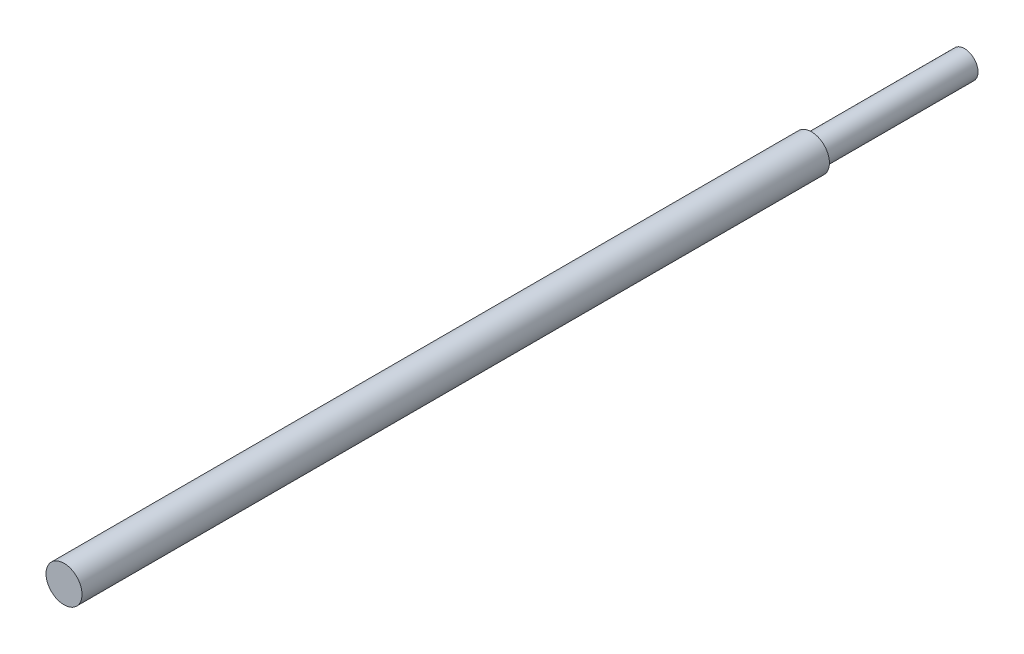
from build123d import *

# Parameters (mm, degrees)
SKETCH1_R           = 8
BOSS_EXTRUDE1_DEPTH = 400
SKETCH2_R           = 10.666186783
SKETCH2_R_2         = 6
CUT_EXTRUDE1_DEPTH  = 68


with BuildPart() as part:
    # Sketch1 → Boss-Extrude1 (new body)
    with BuildSketch(Plane.XY):
        Circle(SKETCH1_R)
    extrude(amount=BOSS_EXTRUDE1_DEPTH)

    # Sketch2 → Cut-Extrude1 (cut)
    with BuildSketch(Plane(origin=(0, 0, 0), x_dir=(-1, 0, 0), z_dir=(0, 0, -1))):
        Circle(SKETCH2_R)
        Circle(SKETCH2_R_2, mode=Mode.SUBTRACT)
    extrude(amount=-CUT_EXTRUDE1_DEPTH, mode=Mode.SUBTRACT)


solid = part.part
